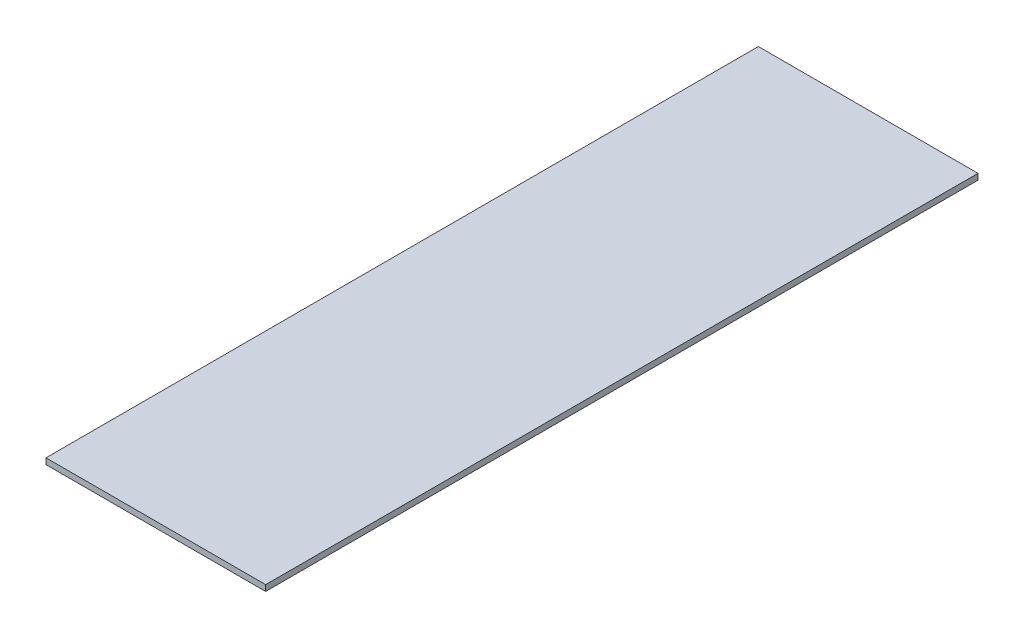
from build123d import *

# Parameters (mm, degrees)
BOSS_EXTRUDE1_DEPTH      = 3.175
BOSS_EXTRUDE1_DEPTH_BACK = 3.175
SKETCH1_W                = 234.95
SKETCH1_H                = 762


with BuildPart() as part:
    # Sketch1 → Boss-Extrude1 (new, two sides: drawn at the far end of the back side and taken through both)
    with BuildSketch(Plane(origin=(0, 0, 0), x_dir=(1, 0, 0), z_dir=(0, 1, 0)).offset(-BOSS_EXTRUDE1_DEPTH_BACK)):
        Rectangle(SKETCH1_W, SKETCH1_H)
    extrude(amount=BOSS_EXTRUDE1_DEPTH + BOSS_EXTRUDE1_DEPTH_BACK)


solid = part.part
